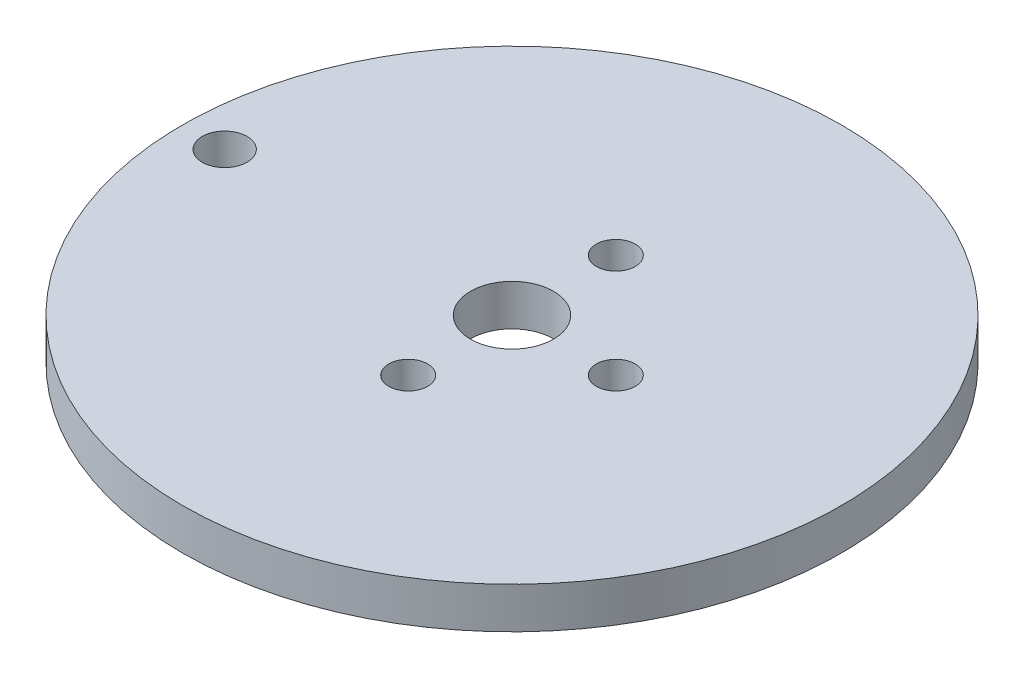
from build123d import *

# Parameters (mm, degrees)
SKETCH1_R           = 25.4
BOSS_EXTRUDE1_DEPTH = 3.175
SKETCH2_R           = 1.7272
CUT_EXTRUDE1_DEPTH  = 4.175
SKETCH3_R           = 3.2004
CUT_EXTRUDE2_DEPTH  = 4.175
SKETCH4_R           = 1.499997
CUT_EXTRUDE3_DEPTH  = 4.175


with BuildPart() as part:
    # Sketch1 → Boss-Extrude1 (new body)
    with BuildSketch(Plane(origin=(0, 0, 0), x_dir=(1, 0, 0), z_dir=(0, 1, 0))):
        Circle(SKETCH1_R)
    extrude(amount=BOSS_EXTRUDE1_DEPTH)

    # Sketch2 → Cut-Extrude1 (cut, through all)
    with BuildSketch(Plane(origin=(0, 3.175, 0), x_dir=(1, 0, 0), z_dir=(0, 1, 0))):
        with Locations((-22.14499, 0)):
            Circle(SKETCH2_R)
    extrude(amount=-CUT_EXTRUDE1_DEPTH, mode=Mode.SUBTRACT)

    # Sketch3 → Cut-Extrude2 (cut, through all)
    with BuildSketch(Plane(origin=(0, 3.175, 0), x_dir=(1, 0, 0), z_dir=(0, 1, 0))):
        Circle(SKETCH3_R)
    extrude(amount=-CUT_EXTRUDE2_DEPTH, mode=Mode.SUBTRACT)

    # Sketch4 → Cut-Extrude3 (cut, through all)
    with BuildSketch(Plane(origin=(0, 3.175, 0), x_dir=(1, 0, 0), z_dir=(0, 1, 0))):
        with Locations((0, 7.999984)):
            Circle(SKETCH4_R)
        with Locations((0, -7.999984)):
            Circle(SKETCH4_R)
        with Locations((7.999984, 0)):
            Circle(SKETCH4_R)
    extrude(amount=-CUT_EXTRUDE3_DEPTH, mode=Mode.SUBTRACT)


solid = part.part
